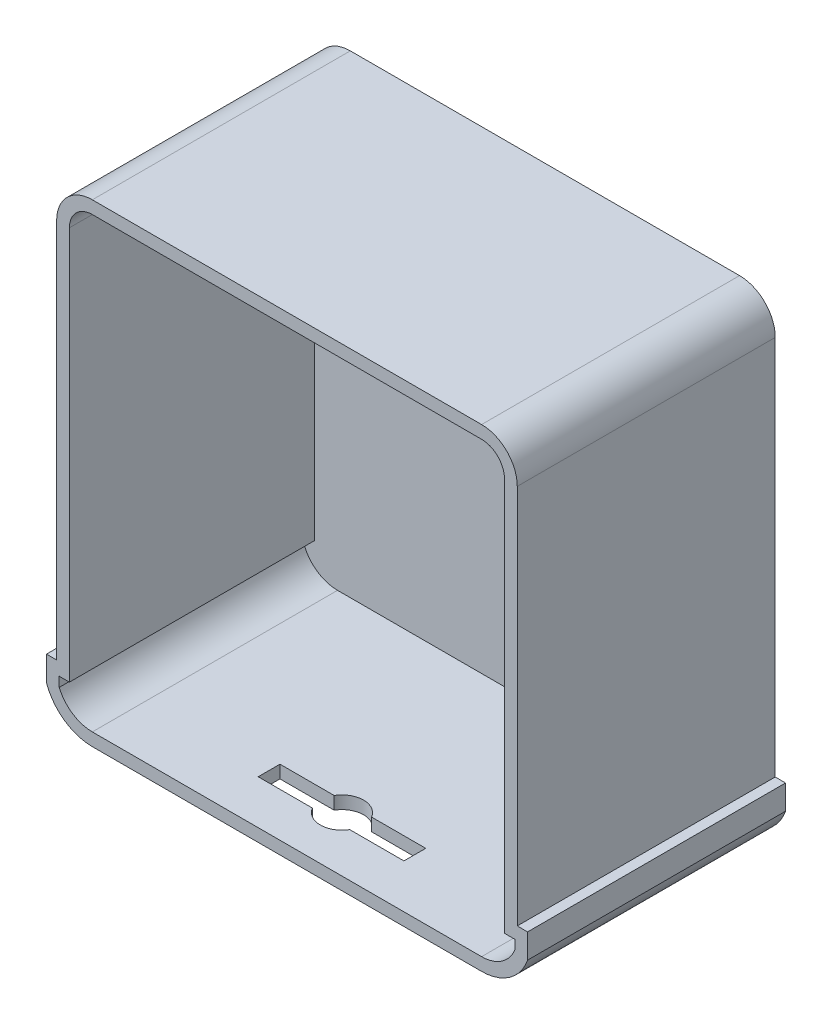
from build123d import *

# Parameters (mm, degrees)
BOSS_EXTRUDE1_DEPTH = 10
BOSS_EXTRUDE2_DEPTH = 192
CUT_EXTRUDE1_DEPTH  = 192


with BuildPart() as part:
    # Sketch1 → Boss-Extrude1 (new body)
    with BuildSketch(Plane.XY):
        with BuildLine():
            Line((-325.411527203, 298.102478214), (-325.411527203, 0))
            Line((-325.411527203, 0), (-333.392551687, 0))
            Line((-333.392551687, 0), (-333.392551687, -19.397521786))
            ThreePointArc((-333.392551687, -19.397521786), (-319.468572459, -37.806041519), (-297.471527203, -44.797521786))
            Line((-297.471527203, -44.797521786), (7.328472797, -44.797521786))
            ThreePointArc((7.328472797, -44.797521786), (29.426688427, -37.734255924), (43.331435707, -19.163341521))
            Line((43.331435707, -19.163341521), (43.331435707, 0))
            Line((43.331435707, 0), (35.268472797, 0))
            Line((35.268472797, 0), (35.268472797, 298.102478214))
            ThreePointArc((35.268472797, 298.102478214), (27.085036263, 317.859041681), (7.328472797, 326.042478214))
            Line((7.328472797, 326.042478214), (-297.471527203, 326.042478214))
            ThreePointArc((-297.471527203, 326.042478214), (-317.22809067, 317.859041681), (-325.411527203, 298.102478214))
        make_face()
    extrude(amount=BOSS_EXTRUDE1_DEPTH)

    # Sketch2 → Boss-Extrude2 (add)
    with BuildSketch(Plane.XY.offset(10)):
        with BuildLine():
            Line((-325.411527203, 298.102478214), (-325.411527203, 0))
            Line((-325.411527203, 0), (-333.392551687, 0))
            Line((-333.392551687, 0), (-333.392551687, -19.397521786))
            ThreePointArc((-333.392551687, -19.397521786), (-319.468572459, -37.806041519), (-297.471527203, -44.797521786))
            Line((-297.471527203, -44.797521786), (7.328472797, -44.797521786))
            ThreePointArc((7.328472797, -44.797521786), (29.426688427, -37.734255924), (43.331435707, -19.163341521))
            Line((43.331435707, -19.163341521), (43.331435707, 0))
            Line((43.331435707, 0), (35.268472797, 0))
            Line((35.268472797, 0), (35.268472797, 298.102478214))
            ThreePointArc((35.268472797, 298.102478214), (27.085036263, 317.859041681), (7.328472797, 326.042478214))
            Line((7.328472797, 326.042478214), (-297.471527203, 326.042478214))
            ThreePointArc((-297.471527203, 326.042478214), (-317.22809067, 317.859041681), (-325.411527203, 298.102478214))
        make_face()
        with BuildLine():
            Line((-315.411527203, 298.102478214), (-315.411527203, -10))
            Line((-315.411527203, -10), (-323.392551687, -10))
            Line((-323.392551687, -10), (-323.392551687, -17.546968301))
            ThreePointArc((-323.392551687, -17.546968301), (-313.039772977, -30.090677271), (-297.471527203, -34.797521786))
            Line((-297.471527203, -34.797521786), (7.328472797, -34.797521786))
            ThreePointArc((7.328472797, -34.797521786), (22.985754076, -30.031178656), (33.331435707, -17.349090679))
            Line((33.331435707, -17.349090679), (33.331435707, -10))
            Line((33.331435707, -10), (25.268472797, -10))
            Line((25.268472797, -10), (25.268472797, 298.102478214))
            ThreePointArc((25.268472797, 298.102478214), (20.013968451, 310.787973869), (7.328472797, 316.042478214))
            Line((7.328472797, 316.042478214), (-297.471527203, 316.042478214))
            ThreePointArc((-297.471527203, 316.042478214), (-310.157022858, 310.787973869), (-315.411527203, 298.102478214))
        make_face(mode=Mode.SUBTRACT)
    extrude(amount=BOSS_EXTRUDE2_DEPTH)

    # Sketch3 → Cut-Extrude1 (cut)
    with BuildSketch(Plane.XZ.offset(44.797521786)):
        with BuildLine():
            ThreePointArc((-130.445711932, 167.470752043), (-145.071527203, 175.87248582), (-159.697342474, 167.470752043))
            Line((-159.697342474, 167.470752043), (-130.445711932, 167.470752043))
        make_face()
        with BuildLine():
            ThreePointArc((-159.697342474, 167.470752043), (-162.002770822, 158.941242201), (-159.697342474, 150.411732359))
            Line((-159.697342474, 150.411732359), (-130.445711932, 150.411732359))
            ThreePointArc((-130.445711932, 150.411732359), (-128.72679943, 154.523450388), (-128.140283584, 158.941242201))
            ThreePointArc((-128.140283584, 158.941242201), (-128.72679943, 163.359034014), (-130.445711932, 167.470752043))
            Line((-130.445711932, 167.470752043), (-159.697342474, 167.470752043))
        make_face()
        with BuildLine():
            ThreePointArc((-128.140283584, 158.941242201), (-128.72679943, 154.523450388), (-130.445711932, 150.411732359))
            Line((-130.445711932, 150.411732359), (-88.003795491, 150.411732359))
            Line((-88.003795491, 150.411732359), (-88.003795491, 167.470752043))
            Line((-88.003795491, 167.470752043), (-130.445711932, 167.470752043))
            ThreePointArc((-130.445711932, 167.470752043), (-128.72679943, 163.359034014), (-128.140283584, 158.941242201))
        make_face()
        with BuildLine():
            Line((-202.139258915, 167.470752043), (-202.139258915, 150.411732359))
            Line((-202.139258915, 150.411732359), (-159.697342474, 150.411732359))
            ThreePointArc((-159.697342474, 150.411732359), (-162.002770822, 158.941242201), (-159.697342474, 167.470752043))
            Line((-159.697342474, 167.470752043), (-202.139258915, 167.470752043))
        make_face()
        with BuildLine():
            Line((-130.445711932, 150.411732359), (-159.697342474, 150.411732359))
            ThreePointArc((-159.697342474, 150.411732359), (-145.071527203, 142.009998582), (-130.445711932, 150.411732359))
        make_face()
    extrude(amount=-CUT_EXTRUDE1_DEPTH, mode=Mode.SUBTRACT)


solid = part.part
